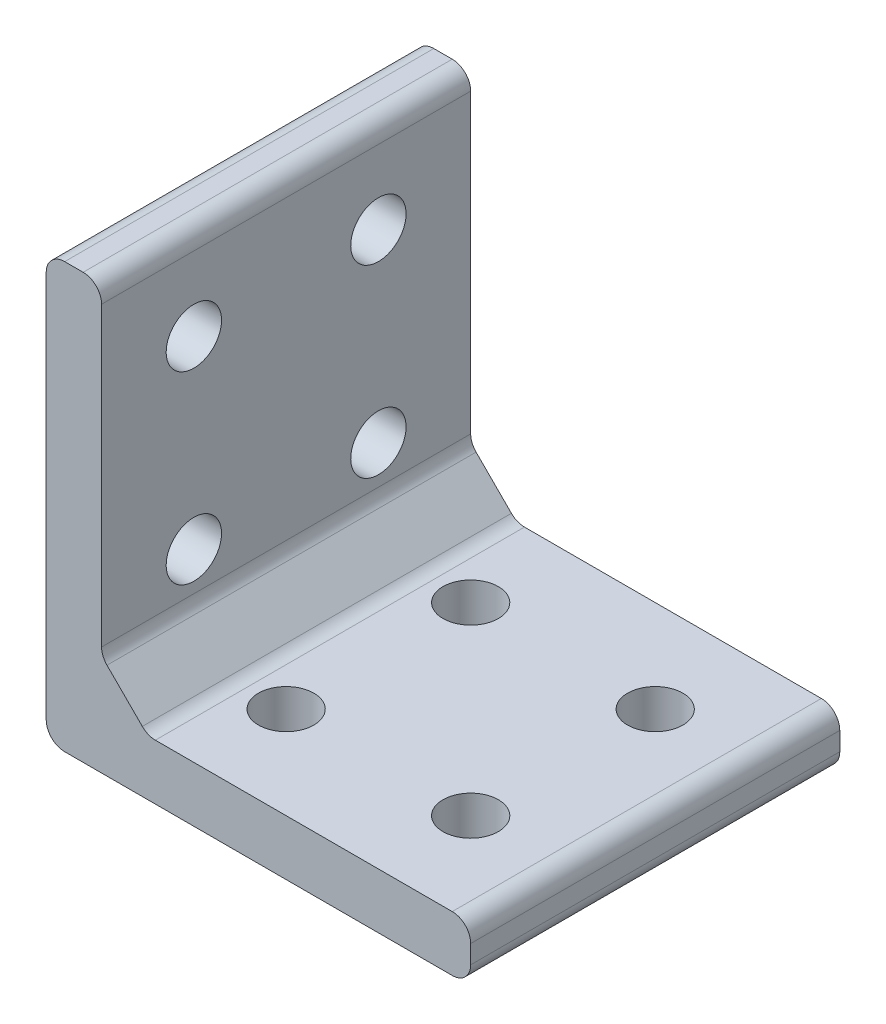
from build123d import *

# Parameters (mm, degrees)
BOSS_EXTRU_1_DEPTH      = 20
ESQUISSE2_R             = 1.5
ENL_V_MAT_EXTRU_1_DEPTH = 20
ESQUISSE3_R             = 1.5
ENL_V_MAT_EXTRU_2_DEPTH = 20
CHANFREIN1_SIZE         = 2.5
CONG_2_R                = 1


with BuildPart() as part:
    # Esquisse1 → Boss.-Extru.1 (new body)
    with BuildSketch(Plane.XY):
        Polygon((23, 0), (0, 0), (0, 23), (3, 23), (3, 3), (23, 3), align=None)
    extrude(amount=BOSS_EXTRU_1_DEPTH)

    # Esquisse2 → Enlèv. mat.-Extru.1 (cut)
    with BuildSketch(Plane(origin=(0, 3, 0), x_dir=(1, 0, 0), z_dir=(0, 1, 0))):
        with Locations((8, -15)):
            Circle(ESQUISSE2_R)
        with Locations((18, -15)):
            Circle(ESQUISSE2_R)
        with Locations((18, -5)):
            Circle(ESQUISSE2_R)
        with Locations((8, -5)):
            Circle(ESQUISSE2_R)
    extrude(amount=-ENL_V_MAT_EXTRU_1_DEPTH, mode=Mode.SUBTRACT)

    # Esquisse3 → Enlèv. mat.-Extru.2 (cut)
    with BuildSketch(Plane(origin=(3, 0, 0), x_dir=(0, 0, -1), z_dir=(1, 0, 0))):
        with Locations((-15, 18)):
            Circle(ESQUISSE3_R)
        with Locations((-5, 18)):
            Circle(ESQUISSE3_R)
        with Locations((-5, 8)):
            Circle(ESQUISSE3_R)
        with Locations((-15, 8)):
            Circle(ESQUISSE3_R)
    extrude(amount=-ENL_V_MAT_EXTRU_2_DEPTH, mode=Mode.SUBTRACT)

    # Chanfrein1
    chanfrein1_edges = [part.edges().sort_by_distance(p)[0] for p in [
        (3, 3, 10),
    ]]
    chamfer(chanfrein1_edges, length=CHANFREIN1_SIZE)

    # Congé2
    cong_2_edges = [part.edges().sort_by_distance(p)[0] for p in [
        (23, 0, 10),
        (0, 0, 10),
        (0, 23, 10),
        (3, 23, 10),
        (23, 3, 10),
        (3, 5.5, 10),
        (5.5, 3, 10),
    ]]
    fillet(cong_2_edges, radius=CONG_2_R)


solid = part.part
